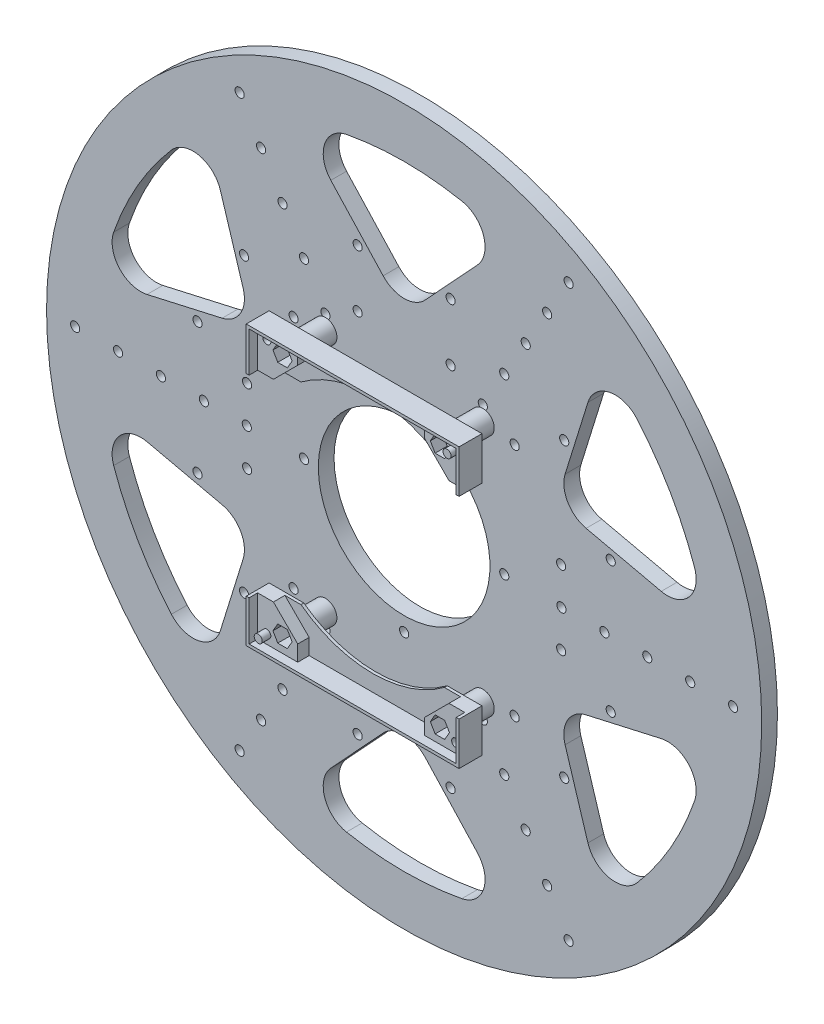
from build123d import *

# Parameters (mm, degrees)
SKETCH_1_R               = 125
EXTRUDE_1_DEPTH          = 5.5
SKETCH_3_R               = 1.6
CUT_EXTRUDE_1_DEPTH      = 6.5
PATTERN_CIRCULAR_1_COUNT = 6
SKETCH_4_R               = 30
SKETCH_4_R_2             = 1.6
CUT_EXTRUDE_2_DEPTH      = 6.5
SKETCH_5_R               = 1.6
CUT_EXTRUDE_3_DEPTH      = 6.5
SKETCH_6_R               = 1.6
CUT_EXTRUDE_4_DEPTH      = 6.5
SKETCH_7_R               = 4
SKETCH_7_R_2             = 1.8
EXTRUDE_2_DEPTH          = 10
EXTRUDE_2_2_DEPTH        = 10
EXTRUDE_2_3_DEPTH        = 10
EXTRUDE_2_4_DEPTH        = 10
EXTRUDE_3_DEPTH          = 1
EXTRUDE_4_DEPTH          = 7
EXTRUDE_5_DEPTH          = 4
SKETCH_12_R              = 1.4
EXTRUDE_6_DEPTH          = 3
CUT_EXTRUDE_5_DEPTH      = 9
SKETCH_14_R              = 1.4
CUT_EXTRUDE_6_DEPTH      = 24.5


with BuildPart() as part:
    # ｽｹｯﾁ1 → ﾎﾞｽ - 押し出し1 (new body)
    with BuildSketch(Plane.XY):
        Circle(SKETCH_1_R)
    extrude(amount=EXTRUDE_1_DEPTH)

    # ｽｹｯﾁ3 → ｶｯﾄ - 押し出し1 (cut, through all)
    with BuildSketch(Plane(origin=(0, 0, 0), x_dir=(-1, 0, 0), z_dir=(0, 0, -1))):
        with Locations((-16.25, 74)):
            Circle(SKETCH_3_R)
        with Locations((-16.25, 54)):
            Circle(SKETCH_3_R)
        with Locations((16.25, 54)):
            Circle(SKETCH_3_R)
        with Locations((16.25, 74)):
            Circle(SKETCH_3_R)
        with BuildLine():
            Line((-25.629768191, 88.978306263), (-7.34049422, 69.209039494))
            ThreePointArc((-7.34049422, 69.209039494), (0, 66), (7.34049422, 69.209039494))
            Line((7.34049422, 69.209039494), (25.629768191, 88.978306263))
            ThreePointArc((25.629768191, 88.978306263), (27.788579257, 98.893878596), (20.165096942, 105.591755669))
            ThreePointArc((20.165096942, 105.591755669), (0, 107.5), (-20.165096942, 105.591755669))
            ThreePointArc((-20.165096942, 105.591755669), (-27.788579257, 98.893878596), (-25.629768191, 88.978306263))
        make_face()
    cut_extrude_1 = extrude(amount=-CUT_EXTRUDE_1_DEPTH, mode=Mode.SUBTRACT)

    # 円形ﾊﾟﾀｰﾝ1: ｶｯﾄ - 押し出し1 ×6 about axis
    pattern_circular_1_axis = Axis((0, 0, 0), (0, 0, 1))
    for i in range(1, PATTERN_CIRCULAR_1_COUNT):
        add(cut_extrude_1.rotate(pattern_circular_1_axis, i * 360 / PATTERN_CIRCULAR_1_COUNT), mode=Mode.SUBTRACT)

    # ｽｹｯﾁ4 → ｶｯﾄ - 押し出し2 (cut, through all)
    with BuildSketch(Plane(origin=(0, 0, 0), x_dir=(-1, 0, 0), z_dir=(0, 0, -1))):
        Circle(SKETCH_4_R)
        with Locations((0, 35)):
            Circle(SKETCH_4_R_2)
        with Locations((35, 0)):
            Circle(SKETCH_4_R_2)
        with Locations((0, -35)):
            Circle(SKETCH_4_R_2)
        with Locations((-35, 0)):
            Circle(SKETCH_4_R_2)
    extrude(amount=-CUT_EXTRUDE_2_DEPTH, mode=Mode.SUBTRACT)

    # ｽｹｯﾁ5 → ｶｯﾄ - 押し出し3 (cut, through all)
    with BuildSketch(Plane(origin=(0, 0, 0), x_dir=(-1, 0, 0), z_dir=(0, 0, -1))):
        with Locations((-27.5, 42.5)):
            Circle(SKETCH_5_R)
        with Locations((27.5, 42.5)):
            Circle(SKETCH_5_R)
        with Locations((-27.5, -42.5)):
            Circle(SKETCH_5_R)
        with Locations((27.5, -42.5)):
            Circle(SKETCH_5_R)
    extrude(amount=-CUT_EXTRUDE_3_DEPTH, mode=Mode.SUBTRACT)

    # ｽｹｯﾁ6 → ｶｯﾄ - 押し出し4 (cut, through all)
    with BuildSketch(Plane(origin=(0, 0, 0), x_dir=(-1, 0, 0), z_dir=(0, 0, -1))):
        with Locations((-115, 0)):
            Circle(SKETCH_6_R)
        with Locations((-100, 0)):
            Circle(SKETCH_6_R)
        with Locations((-85, 0)):
            Circle(SKETCH_6_R)
        with Locations((-70, 0)):
            Circle(SKETCH_6_R)
        with Locations((-55, 0)):
            Circle(SKETCH_6_R)
        with Locations((-57.5, 99.592921435)):
            Circle(SKETCH_6_R)
        with Locations((-50, 86.602540378)):
            Circle(SKETCH_6_R)
        with Locations((-42.5, 73.612159322)):
            Circle(SKETCH_6_R)
        with Locations((-35, 60.621778265)):
            Circle(SKETCH_6_R)
        with Locations((-27.5, 47.631397208)):
            Circle(SKETCH_6_R)
        with Locations((57.5, 99.592921435)):
            Circle(SKETCH_6_R)
        with Locations((50, 86.602540378)):
            Circle(SKETCH_6_R)
        with Locations((42.5, 73.612159322)):
            Circle(SKETCH_6_R)
        with Locations((35, 60.621778265)):
            Circle(SKETCH_6_R)
        with Locations((27.5, 47.631397208)):
            Circle(SKETCH_6_R)
        with Locations((115, 0)):
            Circle(SKETCH_6_R)
        with Locations((100, 0)):
            Circle(SKETCH_6_R)
        with Locations((85, 0)):
            Circle(SKETCH_6_R)
        with Locations((70, 0)):
            Circle(SKETCH_6_R)
        with Locations((55, 0)):
            Circle(SKETCH_6_R)
        with Locations((57.5, -99.592921435)):
            Circle(SKETCH_6_R)
        with Locations((50, -86.602540378)):
            Circle(SKETCH_6_R)
        with Locations((42.5, -73.612159322)):
            Circle(SKETCH_6_R)
        with Locations((35, -60.621778265)):
            Circle(SKETCH_6_R)
        with Locations((27.5, -47.631397208)):
            Circle(SKETCH_6_R)
        with Locations((-57.5, -99.592921435)):
            Circle(SKETCH_6_R)
        with Locations((-50, -86.602540378)):
            Circle(SKETCH_6_R)
        with Locations((-42.5, -73.612159322)):
            Circle(SKETCH_6_R)
        with Locations((-35, -60.621778265)):
            Circle(SKETCH_6_R)
        with Locations((-27.5, -47.631397208)):
            Circle(SKETCH_6_R)
    extrude(amount=-CUT_EXTRUDE_4_DEPTH, mode=Mode.SUBTRACT)


with BuildPart() as body_2:
    # ｽｹｯﾁ7 → ﾎﾞｽ - 押し出し2 (new body)
    with BuildSketch(Plane(origin=(0, 0, 5.5), x_dir=(-1, 0, 0), z_dir=(0, 0, -1))):
        with Locations((-27.5, 42.5)):
            Circle(SKETCH_7_R)
        with Locations((-27.5, 42.5)):
            Circle(SKETCH_7_R_2, mode=Mode.SUBTRACT)
    extrude(amount=-EXTRUDE_2_DEPTH)



with BuildPart() as body_3:
    # ｽｹｯﾁ7 → Extrude 2 2 (new body)
    with BuildSketch(Plane(origin=(0, 0, 5.5), x_dir=(-1, 0, 0), z_dir=(0, 0, -1))):
        with Locations((27.5, 42.5)):
            Circle(SKETCH_7_R)
        with Locations((27.5, 42.5)):
            Circle(SKETCH_7_R_2, mode=Mode.SUBTRACT)
    extrude(amount=-EXTRUDE_2_2_DEPTH)


with BuildPart() as body_4:
    # ｽｹｯﾁ7 → Extrude 2 3 (new body)
    with BuildSketch(Plane(origin=(0, 0, 5.5), x_dir=(-1, 0, 0), z_dir=(0, 0, -1))):
        with Locations((-27.5, -42.5)):
            Circle(SKETCH_7_R)
        with Locations((-27.5, -42.5)):
            Circle(SKETCH_7_R_2, mode=Mode.SUBTRACT)
    extrude(amount=-EXTRUDE_2_3_DEPTH)


with BuildPart() as body_5:
    # ｽｹｯﾁ7 → Extrude 2 4 (new body)
    with BuildSketch(Plane(origin=(0, 0, 5.5), x_dir=(-1, 0, 0), z_dir=(0, 0, -1))):
        with Locations((27.5, -42.5)):
            Circle(SKETCH_7_R)
        with Locations((27.5, -42.5)):
            Circle(SKETCH_7_R_2, mode=Mode.SUBTRACT)
    extrude(amount=-EXTRUDE_2_4_DEPTH)


with BuildPart() as body_2_1:
    add(body_2.part)

    add(body_3.part)  # ﾎﾞｽ - 押し出し3 merges body 3

    add(body_4.part)  # ﾎﾞｽ - 押し出し3 merges body 4

    add(body_5.part)  # ﾎﾞｽ - 押し出し3 merges body 5
    # ｽｹｯﾁ8 → ﾎﾞｽ - 押し出し3 (add)
    with BuildSketch(Plane.XY.offset(15.5)):
        with BuildLine():
            Line((37.2, -48.7), (-37.2, -48.7))
            Line((-37.2, -48.7), (-37.2, -33.7))
            Line((-37.2, -33.7), (-25.066112583, -33.7))
            ThreePointArc((-25.066112583, -33.7), (0, -42), (25.066112583, -33.7))
            Line((25.066112583, -33.7), (37.2, -33.7))
            Line((37.2, -33.7), (37.2, -48.7))
        make_face()
        with BuildLine():
            Line((37.2, 48.7), (-37.2, 48.7))
            Line((-37.2, 48.7), (-37.2, 33.7))
            Line((-37.2, 33.7), (-25.066112583, 33.7))
            ThreePointArc((-25.066112583, 33.7), (0, 42), (25.066112583, 33.7))
            Line((25.066112583, 33.7), (37.2, 33.7))
            Line((37.2, 33.7), (37.2, 48.7))
        make_face()
    extrude(amount=EXTRUDE_3_DEPTH)

    # ｽｹｯﾁ10 → ﾎﾞｽ - 押し出し4 (add)
    with BuildSketch(Plane.XY.offset(16.5)):
        Polygon((37.2, 33.7), (37.2, 48.7), (-37.2, 48.7), (-37.2, 33.7), (-36.2, 33.7), (-36.2, 47.7), (36.2, 47.7), (36.2, 33.7), align=None)
        Polygon((36.2, -33.7), (37.2, -33.7), (37.2, -48.7), (-37.2, -48.7), (-37.2, -33.7), (-36.2, -33.7), (-36.2, -47.7), (36.2, -47.7), align=None)
    extrude(amount=EXTRUDE_4_DEPTH)

    # ｽｹｯﾁ11 → ﾎﾞｽ - 押し出し5 (add)
    with BuildSketch(Plane.XY.offset(16.5)):
        Polygon((-36.2, 47.7), (-36.2, 33.7), (-30.685281374, 33.7), (-22.2, 42.185281374), (-22.2, 47.7), align=None)
        Polygon((22.2, 42.185281374), (30.685281374, 33.7), (36.2, 33.7), (36.2, 47.7), (22.2, 47.7), align=None)
        Polygon((36.2, -47.7), (36.2, -33.7), (30.685281374, -33.7), (22.2, -42.185281374), (22.2, -47.7), align=None)
        Polygon((-22.2, -42.185281374), (-30.685281374, -33.7), (-36.2, -33.7), (-36.2, -47.7), (-22.2, -47.7), align=None)
    extrude(amount=EXTRUDE_5_DEPTH)

    # ｽｹｯﾁ12 → ﾎﾞｽ - 押し出し6 (add)
    with BuildSketch(Plane.XY.offset(20.5)):
        with Locations((-33, 44.5)):
            Circle(SKETCH_12_R)
        with Locations((33, 44.5)):
            Circle(SKETCH_12_R)
        with Locations((-33, -44.5)):
            Circle(SKETCH_12_R)
        with Locations((33, -44.5)):
            Circle(SKETCH_12_R)
    extrude(amount=EXTRUDE_6_DEPTH)

    # ｽｹｯﾁ13 → ｶｯﾄ - 押し出し5 (cut, through all)
    with BuildSketch(Plane(origin=(0, 0, 15.5), x_dir=(-1, 0, 0), z_dir=(0, 0, -1))):
        Polygon((-29.174315781, 39.6), (-25.825684219, 39.6), (-24.151368439, 42.5), (-25.825684219, 45.4), (-29.174315781, 45.4), (-30.848631561, 42.5), align=None)
        Polygon((24.151368439, 42.5), (25.825684219, 39.6), (29.174315781, 39.6), (30.848631561, 42.5), (29.174315781, 45.4), (25.825684219, 45.4), align=None)
        Polygon((25.825684219, -45.4), (29.174315781, -45.4), (30.848631561, -42.5), (29.174315781, -39.6), (25.825684219, -39.6), (24.151368439, -42.5), align=None)
        Polygon((-30.848631561, -42.5), (-29.174315781, -45.4), (-25.825684219, -45.4), (-24.151368439, -42.5), (-25.825684219, -39.6), (-29.174315781, -39.6), align=None)
    extrude(amount=-CUT_EXTRUDE_5_DEPTH, mode=Mode.SUBTRACT)

    # ｽｹｯﾁ14 → ｶｯﾄ - 押し出し6 (cut, through all)
    with BuildSketch(Plane.XY.offset(23.5)):
        with Locations((-33, 44.5)):
            Circle(SKETCH_14_R)
        with Locations((33, -44.5)):
            Circle(SKETCH_14_R)
    extrude(amount=-CUT_EXTRUDE_6_DEPTH, mode=Mode.SUBTRACT)


solid = Compound([part.part, body_2_1.part])
